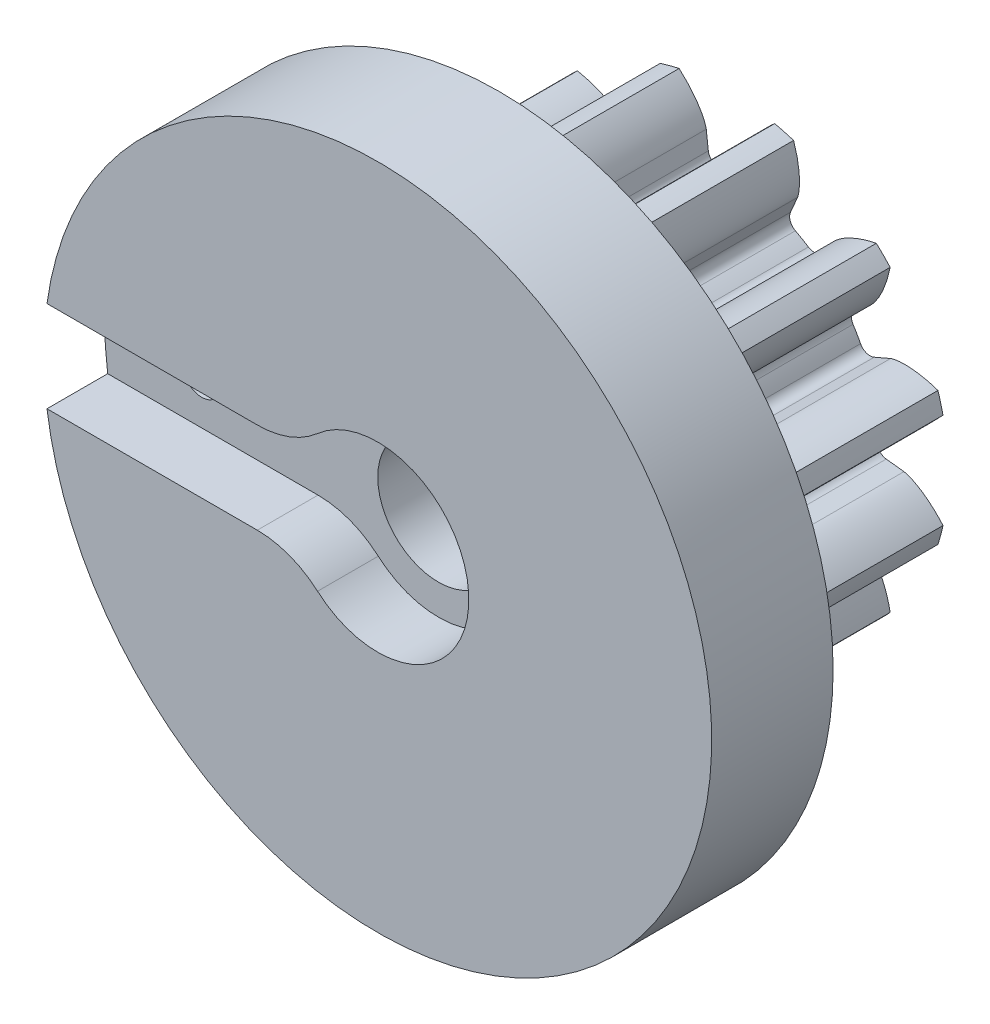
from build123d import *

# Parameters (mm, degrees)
SKETCH3_R                = 7.408333333
BOSS_EXTRUDE1_DEPTH      = 7.62
CUT_EXTRUDE1_START       = -8.62
CUT_EXTRUDE1_DEPTH       = 9.62
FILLET1_R                = 0.355076163
CIRPATTERN1_COUNT        = 12
FILLET1_OF_CIRPATTERN1_R = 0.355076163
SCALE1_SCALE             = 2.5
SKETCH10_R               = 27.94
BOSS_EXTRUDE4_DEPTH      = 10.16
SKETCH11_R               = 5.08
CUT_EXTRUDE5_DEPTH       = 30.21
CUT_EXTRUDE6_DEPTH       = 5.08
SKETCH13_R               = 1.5875
CUT_EXTRUDE12_DEPTH      = 25.1300001
SKETCH16_R               = 2.74955
CUT_EXTRUDE13_DEPTH      = 3.81


with BuildPart() as part:
    # Sketch3 → Boss-Extrude1 (new body)
    with BuildSketch(Plane.XY):
        Circle(SKETCH3_R)
    extrude(amount=-BOSS_EXTRUDE1_DEPTH)

    # Sketch4 → Cut-Extrude1 (cut)
    with BuildSketch(Plane.XY.offset(CUT_EXTRUDE1_START)):
        with BuildLine():
            Line((4.993301754, 0.581811335), (5.926950078, 0.690598508))
            add(Edge.make_bspline(
                [(5.926950078, 0.690598508), (5.929318191, 0.690911872), (5.935944647, 0.691904892), (5.948407954, 0.694232443), (5.96863478, 0.69866684), (5.994230847, 0.70524939), (6.027084964, 0.714822349), (6.065467787, 0.727462413), (6.107282331, 0.74277265), (6.152345854, 0.760950457), (6.196898763, 0.780422108), (6.240942495, 0.801081108), (6.284441008, 0.822769247), (6.336662498, 0.8503395), (6.398612769, 0.885198626), (6.469984516, 0.92853373), (6.54965538, 0.980716028), (6.629400976, 1.037091207), (6.706647925, 1.095172788), (6.78320647, 1.156800213), (6.856219389, 1.218511327), (6.930432721, 1.285554849), (6.998115798, 1.348944008), (7.07205666, 1.423150182), (7.131183599, 1.483972917), (7.190627906, 1.549410219), (7.219315962, 1.581641114), (7.233873511, 1.598273068)],
                knots=[0, 0, 0, 0, 0, 0.005376749, 0.015083688, 0.02853182, 0.046610139, 0.064854849, 0.092110525, 0.119476176, 0.146842496, 0.174208854, 0.201574956, 0.228941013, 0.256307345, 0.307035032, 0.361767352, 0.416499661, 0.471231937, 0.525964282, 0.580696615, 0.635428982, 0.690161387, 0.744893688, 0.799626082, 0.854358408, 0.909090915, 0.909090915, 0.909090915, 0.909090915, 0.909090915], degree=4))
            ThreePointArc((7.233873511, 1.598273068), (7.408333333, 0), (7.233873511, -1.598273068))
            add(Edge.make_bspline(
                [(5.926950078, -0.690598508), (5.929318191, -0.690911872), (5.935944647, -0.691904892), (5.948407954, -0.694232443), (5.96863478, -0.69866684), (5.994230847, -0.70524939), (6.027084964, -0.714822349), (6.065467787, -0.727462413), (6.107282331, -0.74277265), (6.152345854, -0.760950457), (6.196898763, -0.780422108), (6.240942495, -0.801081108), (6.284441008, -0.822769247), (6.336662498, -0.8503395), (6.398612769, -0.885198626), (6.469984516, -0.92853373), (6.54965538, -0.980716028), (6.629400976, -1.037091207), (6.706647925, -1.095172788), (6.78320647, -1.156800213), (6.856219389, -1.218511327), (6.930432721, -1.285554849), (6.998115798, -1.348944008), (7.07205666, -1.423150182), (7.131183599, -1.483972917), (7.190627906, -1.549410219), (7.219315962, -1.581641114), (7.233873511, -1.598273068)],
                knots=[0, 0, 0, 0, 0, 0.005376749, 0.015083688, 0.02853182, 0.046610139, 0.064854849, 0.092110525, 0.119476176, 0.146842496, 0.174208854, 0.201574956, 0.228941013, 0.256307345, 0.307035032, 0.361767352, 0.416499661, 0.471231937, 0.525964282, 0.580696615, 0.635428982, 0.690161387, 0.744893688, 0.799626082, 0.854358408, 0.909090915, 0.909090915, 0.909090915, 0.909090915, 0.909090915], degree=4))
            Line((5.926950078, -0.690598508), (4.993301754, -0.581811335))
            ThreePointArc((4.993301754, -0.581811335), (5.027083333, 0), (4.993301754, 0.581811335))
        make_face()
    cut_extrude1 = extrude(amount=CUT_EXTRUDE1_DEPTH, mode=Mode.SUBTRACT)

    # Fillet1
    fillet1_edges = [part.edges().sort_by_distance(p)[0] for p in [
        (4.993301754, -0.581811335, -3.81),
        (4.993301754, 0.581811335, -3.81),
    ]]
    fillet(fillet1_edges, radius=FILLET1_R)

    # CirPattern1: Cut-Extrude1 ×12 about axis
    cirpattern1_axis = Axis((0, 0, 6.35), (0, 0, -1))
    for i in range(1, CIRPATTERN1_COUNT):
        add(cut_extrude1.rotate(cirpattern1_axis, i * 360 / CIRPATTERN1_COUNT), mode=Mode.SUBTRACT)

    # Fillet1 of CirPattern1
    fillet1_of_cirpattern1_edges = [part.edges().sort_by_distance(p)[0] for p in [
        (4.0334205, -3.000514274, -3.81),
        (4.615231836, -1.99278748, -3.81),
        (1.99278748, -4.615231836, -3.81),
        (3.000514274, -4.0334205, -3.81),
        (-0.581811335, -4.993301754, -3.81),
        (0.581811335, -4.993301754, -3.81),
        (-3.000514274, -4.0334205, -3.81),
        (-1.99278748, -4.615231836, -3.81),
        (-4.615231836, -1.99278748, -3.81),
        (-4.0334205, -3.000514274, -3.81),
        (-4.993301754, 0.581811335, -3.81),
        (-4.993301754, -0.581811335, -3.81),
        (-4.0334205, 3.000514274, -3.81),
        (-4.615231836, 1.99278748, -3.81),
        (-1.99278748, 4.615231836, -3.81),
        (-3.000514274, 4.0334205, -3.81),
        (0.581811335, 4.993301754, -3.81),
        (-0.581811335, 4.993301754, -3.81),
        (3.000514274, 4.0334205, -3.81),
        (1.99278748, 4.615231836, -3.81),
        (4.615231836, 1.99278748, -3.81),
        (4.0334205, 3.000514274, -3.81),
    ]]
    fillet(fillet1_of_cirpattern1_edges, radius=FILLET1_OF_CIRPATTERN1_R)


with BuildPart() as part_1:
    # Scale1: scaled about (0, 0, 0)
    add(part.part.scale(SCALE1_SCALE))

    # Sketch10 → Boss-Extrude4 (add)
    with BuildSketch(Plane.XY):
        Circle(SKETCH10_R)
    extrude(amount=BOSS_EXTRUDE4_DEPTH)

    # Sketch11 → Cut-Extrude5 (cut, through all)
    with BuildSketch(Plane(origin=(0, 0, -19.05), x_dir=(-1, 0, 0), z_dir=(0, 0, -1))):
        Circle(SKETCH11_R)
    extrude(amount=-CUT_EXTRUDE5_DEPTH, mode=Mode.SUBTRACT)

    # Sketch12 → Cut-Extrude6 (cut)
    with BuildSketch(Plane.XY.offset(10.16)):
        with BuildLine():
            Line((-10.080312495, -3.81), (-28.438556916, -3.81))
            Line((-28.438556916, -3.81), (-28.438556916, 3.81))
            Line((-28.438556916, 3.81), (-10.080312495, 3.81))
            ThreePointArc((-10.080312495, 3.81), (-7.386235659, 4.302142678), (-5.040156248, 5.715))
            ThreePointArc((-5.040156248, 5.715), (7.62, 0), (-5.040156248, -5.715))
            ThreePointArc((-5.040156248, -5.715), (-7.386235659, -4.302142678), (-10.080312495, -3.81))
        make_face()
    extrude(amount=-CUT_EXTRUDE6_DEPTH, mode=Mode.SUBTRACT)

    # Sketch13 → Cut-Extrude12 (cut, through all)
    with BuildSketch(Plane.XY.offset(5.08)):
        with Locations((-19.812, 0)):
            Circle(SKETCH13_R)
    extrude(amount=-CUT_EXTRUDE12_DEPTH, mode=Mode.SUBTRACT)

    # Sketch16 → Cut-Extrude13 (cut)
    with BuildSketch(Plane(origin=(0, 0, 0), x_dir=(-1, 0, 0), z_dir=(0, 0, -1))):
        with Locations((19.812, 0)):
            Circle(SKETCH16_R)
    extrude(amount=-CUT_EXTRUDE13_DEPTH, mode=Mode.SUBTRACT)


solid = part_1.part
